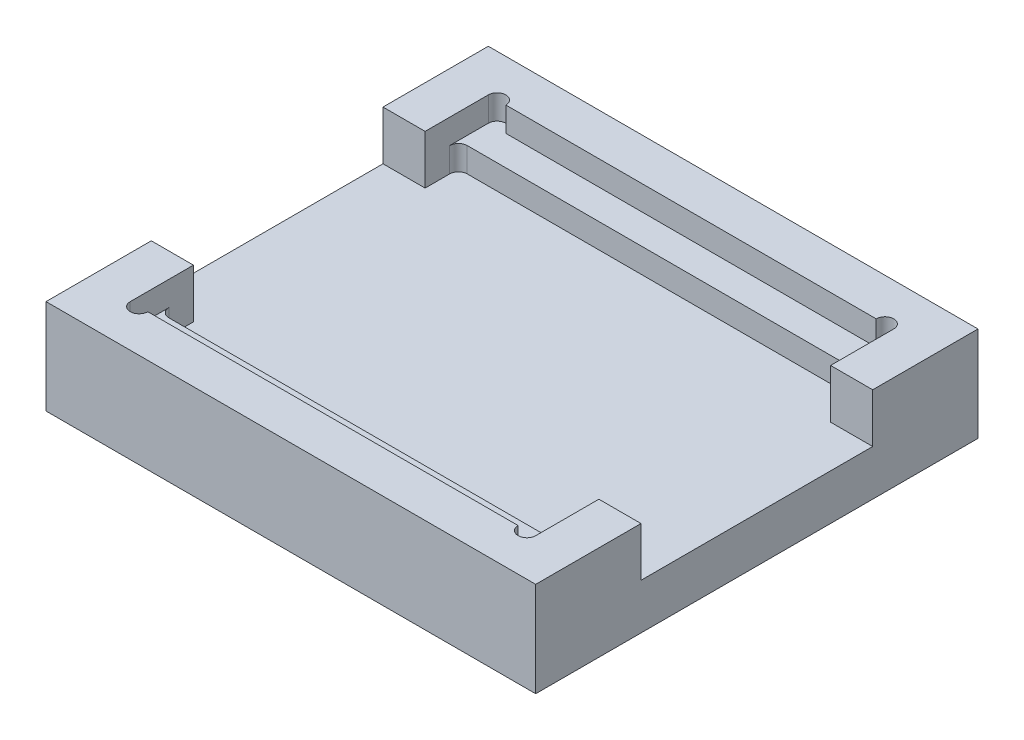
from build123d import *

# Parameters (mm, degrees)
SKETCH1_W           = 139.5
SKETCH1_H           = 126
BOSS_EXTRUDE1_DEPTH = 27
SKETCH2_W           = 115.5
SKETCH2_H           = 102
CUT_EXTRUDE1_DEPTH  = 7
SKETCH3_W           = 115.5
SKETCH3_H           = 85
CUT_EXTRUDE2_DEPTH  = 7
SKETCH4_W           = 12
SKETCH4_H           = 66
CUT_EXTRUDE3_DEPTH  = 14
SKETCH5_W           = 12
SKETCH5_H           = 66
CUT_EXTRUDE4_DEPTH  = 14
CUT_EXTRUDE5_DEPTH  = 7
FILLET1_R           = 2.5


with BuildPart() as part:
    # Sketch1 → Boss-Extrude1 (new body)
    with BuildSketch(Plane(origin=(0, 0, 0), x_dir=(1, 0, 0), z_dir=(0, 1, 0))):
        with Locations((69.75, 63)):
            Rectangle(SKETCH1_W, SKETCH1_H)
    extrude(amount=BOSS_EXTRUDE1_DEPTH)

    # Sketch2 → Cut-Extrude1 (cut)
    with BuildSketch(Plane(origin=(0, 27, 0), x_dir=(1, 0, 0), z_dir=(0, 1, 0))):
        with Locations((69.75, 63)):
            Rectangle(SKETCH2_W, SKETCH2_H)
    extrude(amount=-CUT_EXTRUDE1_DEPTH, mode=Mode.SUBTRACT)

    # Sketch3 → Cut-Extrude2 (cut)
    with BuildSketch(Plane(origin=(0, 20, 0), x_dir=(1, 0, 0), z_dir=(0, 1, 0))):
        with Locations((69.75, 63)):
            Rectangle(SKETCH3_W, SKETCH3_H)
    extrude(amount=-CUT_EXTRUDE2_DEPTH, mode=Mode.SUBTRACT)

    # Sketch4 → Cut-Extrude3 (cut)
    with BuildSketch(Plane(origin=(0, 27, 0), x_dir=(1, 0, 0), z_dir=(0, 1, 0))):
        with Locations((6, 63)):
            Rectangle(SKETCH4_W, SKETCH4_H)
    extrude(amount=-CUT_EXTRUDE3_DEPTH, mode=Mode.SUBTRACT)

    # Sketch5 → Cut-Extrude4 (cut)
    with BuildSketch(Plane(origin=(0, 27, 0), x_dir=(1, 0, 0), z_dir=(0, 1, 0))):
        with Locations((133.5, 63)):
            Rectangle(SKETCH5_W, SKETCH5_H)
    extrude(amount=-CUT_EXTRUDE4_DEPTH, mode=Mode.SUBTRACT)

    # Sketch6 → Cut-Extrude5 (cut)
    with BuildSketch(Plane(origin=(0, 27, 0), x_dir=(1, 0, 0), z_dir=(0, 1, 0))):
        with BuildLine():
            Line((12, 12), (17, 12))
            ThreePointArc((17, 12), (14.5, 9.5), (12, 12))
        make_face()
        with BuildLine():
            Line((122.5, 12), (127.5, 12))
            ThreePointArc((127.5, 12), (125, 9.5), (122.5, 12))
        make_face()
        with BuildLine():
            Line((12, 114), (17, 114))
            ThreePointArc((17, 114), (14.5, 116.5), (12, 114))
        make_face()
        with BuildLine():
            Line((122.5, 114), (127.5, 114))
            ThreePointArc((127.5, 114), (125, 116.5), (122.5, 114))
        make_face()
    extrude(amount=-CUT_EXTRUDE5_DEPTH, mode=Mode.SUBTRACT)

    # Fillet1
    fillet1_edges = [part.edges().sort_by_distance(p)[0] for p in [
        (127.5, 16.5, -105.5),
        (127.5, 16.5, -20.5),
        (12, 16.5, -20.5),
        (12, 16.5, -105.5),
    ]]
    fillet(fillet1_edges, radius=FILLET1_R)


solid = part.part
